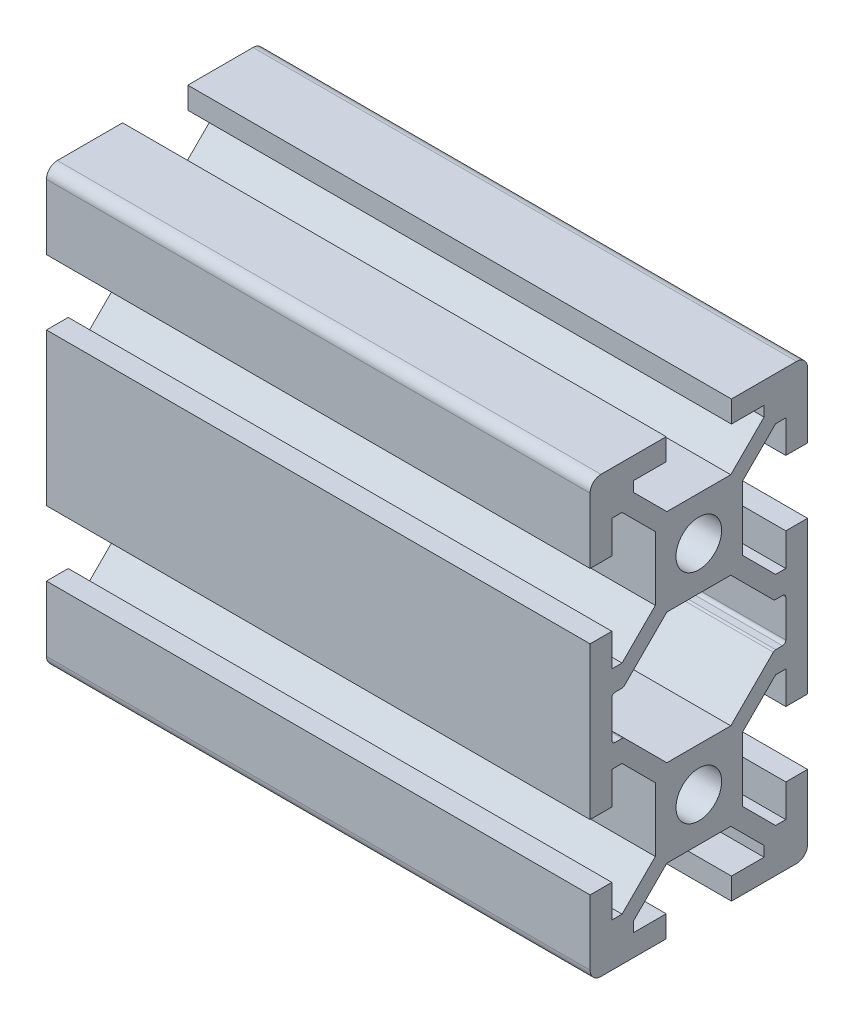
from build123d import *

# Parameters (mm, degrees)
SKETCH1_R           = 2.1
BOSS_EXTRUDE1_DEPTH = 50


with BuildPart() as part:
    # Sketch1 → Boss-Extrude1 (new body)
    with BuildSketch(Plane(origin=(0, 0, 0), x_dir=(0, 0, -1), z_dir=(1, 0, 0))):
        with BuildLine():
            Line((-10, -13), (-10, -19))
            ThreePointArc((-10, -19), (-9.707106781, -19.707106781), (-9, -20))
            Line((-9, -20), (-3, -20))
            Line((-3, -20), (-3, -18))
            Line((-3, -18), (-6, -18))
            Line((-6, -18), (-6, -17.060660172))
            Line((-6, -17.060660172), (-2.939339828, -14))
            Line((-2.939339828, -14), (2.939339828, -14))
            Line((2.939339828, -14), (6, -17.060660172))
            Line((6, -17.060660172), (6, -18))
            Line((6, -18), (3, -18))
            Line((3, -18), (3, -20))
            Line((3, -20), (9, -20))
            ThreePointArc((9, -20), (9.707106781, -19.707106781), (10, -19))
            Line((10, -19), (10, -13))
            Line((10, -13), (8, -13))
            Line((8, -13), (8, -16))
            Line((8, -16), (7.060660172, -16))
            Line((7.060660172, -16), (4, -12.939339828))
            Line((4, -12.939339828), (4, -7.060660172))
            Line((4, -7.060660172), (7.060660172, -4))
            Line((7.060660172, -4), (8, -4))
            Line((8, -4), (8, -7))
            Line((8, -7), (10, -7))
            Line((10, -7), (10, 7))
            Line((10, 7), (8, 7))
            Line((8, 7), (8, 4))
            Line((8, 4), (7.060660172, 4))
            Line((7.060660172, 4), (4, 7.060660172))
            Line((4, 7.060660172), (4, 12.939339828))
            Line((4, 12.939339828), (7.060660172, 16))
            Line((7.060660172, 16), (8, 16))
            Line((8, 16), (8, 13))
            Line((8, 13), (10, 13))
            Line((10, 13), (10, 19))
            ThreePointArc((10, 19), (9.707106781, 19.707106781), (9, 20))
            Line((9, 20), (3, 20))
            Line((3, 20), (3, 18))
            Line((3, 18), (6, 18))
            Line((6, 18), (6, 17.060660172))
            Line((6, 17.060660172), (2.939339828, 14))
            Line((2.939339828, 14), (-2.939339828, 14))
            Line((-2.939339828, 14), (-6, 17.060660172))
            Line((-6, 17.060660172), (-6, 18))
            Line((-6, 18), (-3, 18))
            Line((-3, 18), (-3, 20))
            Line((-3, 20), (-9, 20))
            ThreePointArc((-9, 20), (-9.707106781, 19.707106781), (-10, 19))
            Line((-10, 19), (-10, 13))
            Line((-10, 13), (-8, 13))
            Line((-8, 13), (-8, 16))
            Line((-8, 16), (-7.060660172, 16))
            Line((-7.060660172, 16), (-4, 12.939339828))
            Line((-4, 12.939339828), (-4, 7.060660172))
            Line((-4, 7.060660172), (-7.060660172, 4))
            Line((-7.060660172, 4), (-8, 4))
            Line((-8, 4), (-8, 7))
            Line((-8, 7), (-10, 7))
            Line((-10, 7), (-10, -7))
            Line((-10, -7), (-8, -7))
            Line((-8, -7), (-8, -4))
            Line((-8, -4), (-7.060660172, -4))
            Line((-7.060660172, -4), (-4, -7.060660172))
            Line((-4, -7.060660172), (-4, -12.939339828))
            Line((-4, -12.939339828), (-7.060660172, -16))
            Line((-7.060660172, -16), (-8, -16))
            Line((-8, -16), (-8, -13))
            Line((-8, -13), (-10, -13))
        make_face()
        with Locations((0, 10)):
            Circle(SKETCH1_R, mode=Mode.SUBTRACT)
        with Locations((0, -10)):
            Circle(SKETCH1_R, mode=Mode.SUBTRACT)
        with BuildLine():
            Line((-8, 1.7), (-8, -1.7))
            ThreePointArc((-8, -1.7), (-7.912132034, -1.912132034), (-7.7, -2))
            Line((-7.7, -2), (-7.063603897, -2))
            ThreePointArc((-7.063603897, -2), (-6.948798867, -2.02283614), (-6.851471863, -2.087867966))
            Line((-6.851471863, -2.087867966), (-2.939339828, -6))
            Line((-2.939339828, -6), (2.939339828, -6))
            Line((2.939339828, -6), (6.851471863, -2.087867966))
            ThreePointArc((6.851471863, -2.087867966), (6.948798867, -2.02283614), (7.063603897, -2))
            Line((7.063603897, -2), (7.7, -2))
            ThreePointArc((7.7, -2), (7.912132034, -1.912132034), (8, -1.7))
            Line((8, -1.7), (8, 1.7))
            ThreePointArc((8, 1.7), (7.912132034, 1.912132034), (7.7, 2))
            Line((7.7, 2), (7.063603897, 2))
            ThreePointArc((7.063603897, 2), (6.948798867, 2.02283614), (6.851471863, 2.087867966))
            Line((6.851471863, 2.087867966), (2.939339828, 6))
            Line((2.939339828, 6), (-2.939339828, 6))
            Line((-2.939339828, 6), (-6.851471863, 2.087867966))
            ThreePointArc((-6.851471863, 2.087867966), (-6.948798867, 2.02283614), (-7.063603897, 2))
            Line((-7.063603897, 2), (-7.7, 2))
            ThreePointArc((-7.7, 2), (-7.912132034, 1.912132034), (-8, 1.7))
        make_face(mode=Mode.SUBTRACT)
    extrude(amount=BOSS_EXTRUDE1_DEPTH)


solid = part.part
